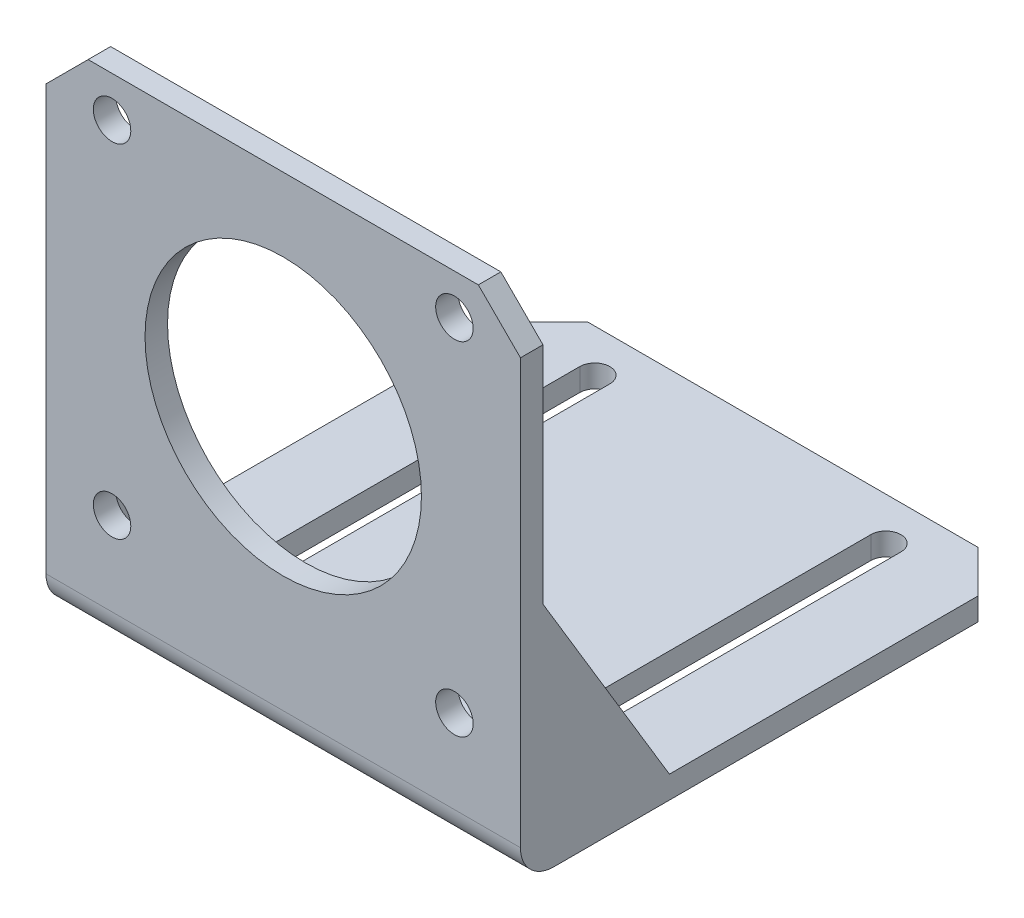
from build123d import *

# Parameters (mm, degrees)
BOSS_EXTRUDE1_DEPTH     = 65.33
CHAMFER1_SIZE           = 5.8
BOSS_EXTRUDE2_DEPTH     = 2.52
BOSS_EXTRUDE3_DEPTH     = 2.52
SKETCH4_R               = 19.03
SKETCH4_R_2             = 2.58
CUT_EXTRUDE1_DEPTH      = 4.1
CUT_EXTRUDE2_DEPTH      = 66.7
CUT_EXTRUDE2_DEPTH_BACK = 4.1


with BuildPart() as part:
    # Sketch1 → Boss-Extrude1 (new body)
    with BuildSketch(Plane(origin=(0, 0, 0), x_dir=(0, 0, -1), z_dir=(1, 0, 0))):
        with BuildLine():
            Line((0, 0), (0, 64.22))
            Line((0, 64.22), (-3.1, 64.22))
            Line((-3.1, 64.22), (-3.1, 0))
            ThreePointArc((-3.1, 0), (-1.758549058, -3.238549058), (1.48, -4.58))
            Line((1.48, -4.58), (65.7, -4.58))
            Line((65.7, -4.58), (65.7, -1.48))
            Line((65.7, -1.48), (1.48, -1.48))
            ThreePointArc((1.48, -1.48), (0.433481964, -1.046518036), (0, 0))
        make_face()
    extrude(amount=BOSS_EXTRUDE1_DEPTH)

    # Chamfer1
    chamfer1_edges = [part.edges().sort_by_distance(p)[0] for p in [
        (65.33, 64.22, 1.55),
        (65.33, -3.03, -65.7),
        (0, -3.03, -65.7),
        (0, 64.22, 1.55),
    ]]
    chamfer(chamfer1_edges, length=CHAMFER1_SIZE)

    # Sketch2 → Boss-Extrude2 (add)
    with BuildSketch(Plane(origin=(65.33, 0, 0), x_dir=(0, 0, -1), z_dir=(1, 0, 0))):
        Polygon((0, 27.49), (17.41, -1.48), (0, -1.48), align=None)
    extrude(amount=-BOSS_EXTRUDE2_DEPTH)

    # Sketch3 → Boss-Extrude3 (add)
    with BuildSketch(Plane.ZY):
        Polygon((0, 27.49), (-17.41, -1.48), (0, -1.48), align=None)
    extrude(amount=-BOSS_EXTRUDE3_DEPTH)

    # Sketch4 → Cut-Extrude1 (cut, through all)
    with BuildSketch(Plane(origin=(0, 0, 0), x_dir=(-1, 0, 0), z_dir=(0, 0, -1))):
        with Locations((-32.665, 35.09)):
            Circle(SKETCH4_R)
        with Locations((-56.235, 58.66)):
            Circle(SKETCH4_R_2)
        with Locations((-9.095, 58.66)):
            Circle(SKETCH4_R_2)
        with Locations((-9.095, 11.52)):
            Circle(SKETCH4_R_2)
        with Locations((-56.235, 11.52)):
            Circle(SKETCH4_R_2)
    extrude(amount=-CUT_EXTRUDE1_DEPTH, mode=Mode.SUBTRACT)

    # Sketch5 → Cut-Extrude2 (cut, two sides)
    with BuildSketch(Plane(origin=(0, -1.48, 0), x_dir=(1, 0, 0), z_dir=(0, 1, 0))) as cut_extrude2_sk:
        with BuildLine():
            Line((50.635, 9.67), (50.635, 59.84))
            ThreePointArc((50.635, 59.84), (52.705, 61.91), (54.775, 59.84))
            Line((54.775, 59.84), (54.775, 9.67))
            ThreePointArc((54.775, 9.67), (52.705, 7.6), (50.635, 9.67))
        make_face()
        with BuildLine():
            Line((10.555, 9.67), (10.555, 59.84))
            ThreePointArc((10.555, 59.84), (12.625, 61.91), (14.695, 59.84))
            Line((14.695, 59.84), (14.695, 9.67))
            ThreePointArc((14.695, 9.67), (12.625, 7.6), (10.555, 9.67))
        make_face()
    extrude(amount=CUT_EXTRUDE2_DEPTH, mode=Mode.SUBTRACT)
    extrude(cut_extrude2_sk.sketch, amount=-CUT_EXTRUDE2_DEPTH_BACK, mode=Mode.SUBTRACT)


solid = part.part
